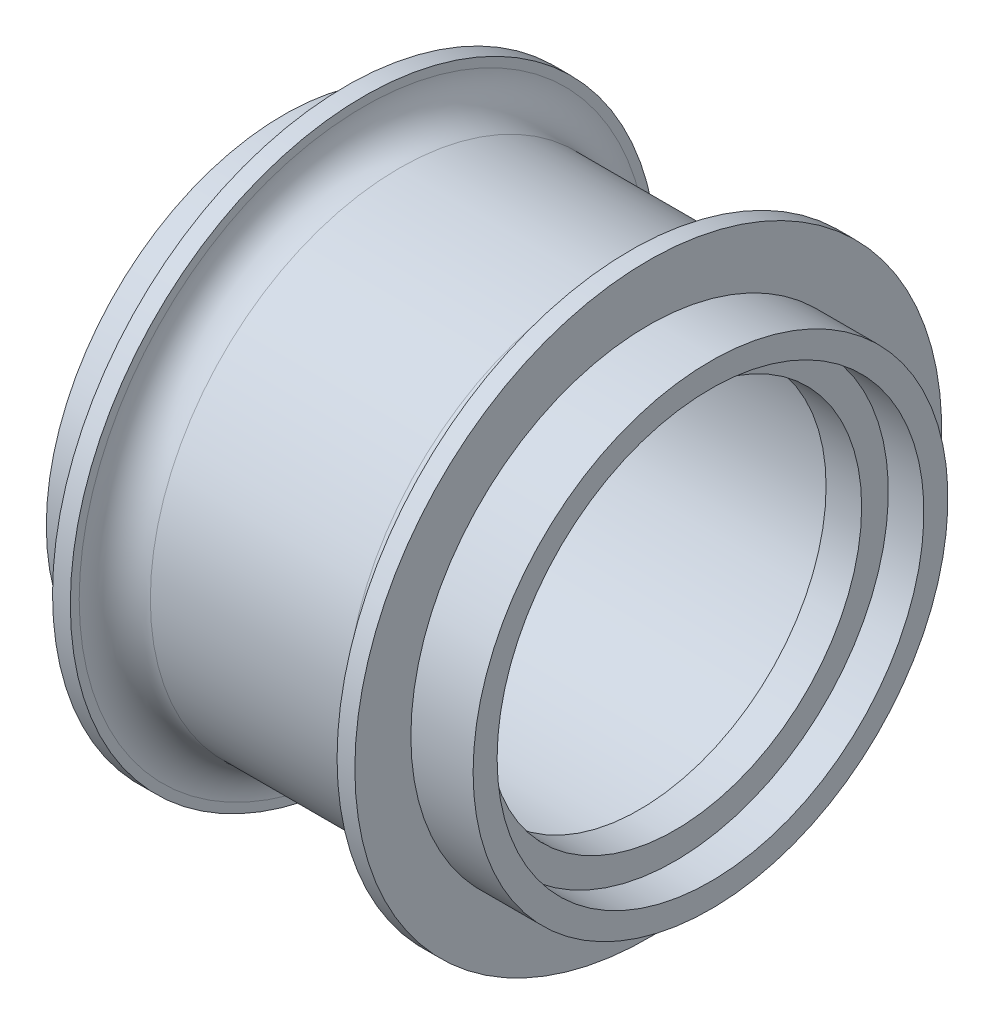
from build123d import *


with BuildPart() as part:
    # Szkic1 → Obrót1 (revolve)
    with BuildSketch(Plane.XY):
        with BuildLine():
            Line((-12, 12), (-9.3, 12))
            Line((-9.3, 12), (-9.3, 12.6))
            Line((-9.3, 12.6), (-8, 12.6))
            Line((-8, 12.6), (-8, 12))
            Line((-8, 12), (8, 12))
            Line((8, 12), (8, 10.5))
            Line((8, 10.5), (10, 10.5))
            Line((10, 10.5), (10, 12))
            Line((10, 12), (12, 12))
            Line((12, 12), (12, 13.35))
            Line((12, 13.35), (8.5, 13.35))
            Line((8.5, 13.35), (8.5, 16.5))
            Line((8.5, 16.5), (7.5, 16.5))
            Line((7.5, 16.5), (7.5, 16))
            ThreePointArc((7.5, 16), (6.914213562, 14.585786438), (5.5, 14))
            Line((5.5, 14), (-5.5, 14))
            ThreePointArc((-5.5, 14), (-6.914213562, 14.585786438), (-7.5, 16))
            Line((-7.5, 16), (-7.5, 16.5))
            Line((-7.5, 16.5), (-8.5, 16.5))
            Line((-8.5, 16.5), (-8.5, 13.35))
            Line((-8.5, 13.35), (-12, 13.35))
            Line((-12, 13.35), (-12, 12))
        make_face()
    revolve(axis=Axis((-7.001985985, 0, 0), (1, 0, 0)))


solid = part.part
